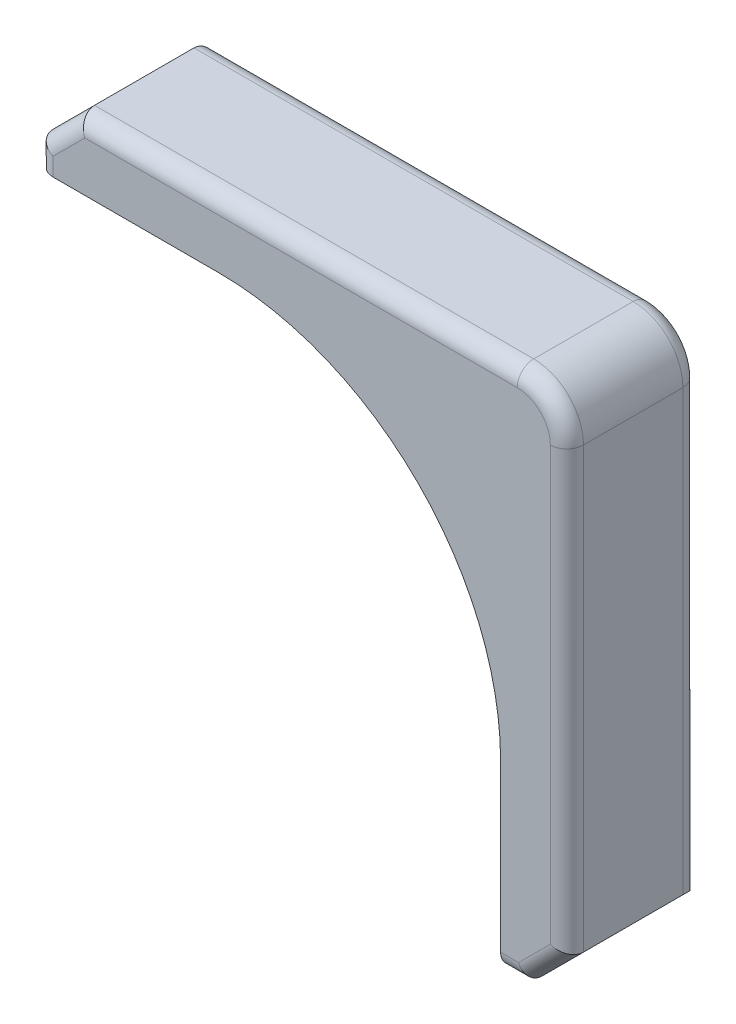
from build123d import *

# Parameters (mm, degrees)
EXTRUDE_1_DEPTH = 8
FILLET_1_R      = 1


with BuildPart() as part:
    # Эскиз1 → Бобышка-Вытянуть1 (new body)
    with BuildSketch(Plane.XY):
        with BuildLine():
            Line((-8.5, 21), (18, 21))
            ThreePointArc((18, 21), (20.121320344, 20.121320344), (21, 18))
            Line((21, 18), (21, -8.5))
            Line((21, -8.5), (18.5, -11))
            Line((18.5, -11), (17, -11))
            Line((17, -11), (17, 0))
            ThreePointArc((17, 0), (12.02081528, 12.02081528), (0, 17))
            Line((0, 17), (-11, 17))
            Line((-11, 17), (-11, 18.5))
            Line((-11, 18.5), (-8.5, 21))
        make_face()
    extrude(amount=EXTRUDE_1_DEPTH)

    # Скругление1
    fillet_1_edges = [part.edges().sort_by_distance(p)[0] for p in [
        (21, 4.75, 0),
        (-11, 17.75, 0),
        (-9.75, 19.75, 0),
        (17.75, -11, 8),
        (19.75, -9.75, 8),
        (21, 4.75, 8),
        (20.121320344, 20.121320344, 8),
        (4.75, 21, 8),
        (-9.75, 19.75, 8),
        (-11, 17.75, 8),
        (4.75, 21, 0),
        (20.121320344, 20.121320344, 0),
    ]]
    fillet(fillet_1_edges, radius=FILLET_1_R)


solid = part.part
